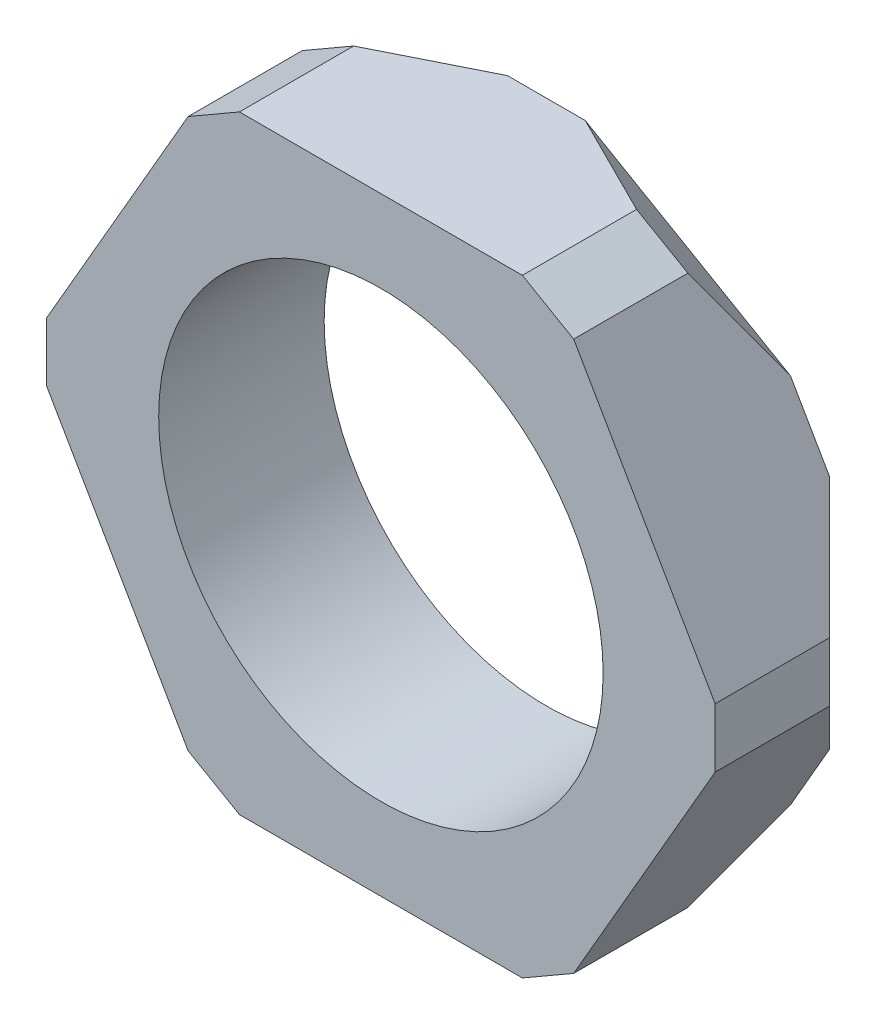
from build123d import *

# Parameters (mm, degrees)
SKETCH1_R           = 6.5
BOSS_EXTRUDE1_DEPTH = 4.84
CHAMFER1_SIZE       = 1
CHAMFER2_SIZE       = 1.5


with BuildPart() as part:
    # Sketch1 → Boss-Extrude1 (new body)
    with BuildSketch(Plane.XY):
        Polygon((5.138417396, 8.9), (-5.138417396, 8.9), (-10.276834792, 0), (-5.138417396, -8.9), (5.138417396, -8.9), (10.276834792, 0), align=None)
        Circle(SKETCH1_R, mode=Mode.SUBTRACT)
    extrude(amount=BOSS_EXTRUDE1_DEPTH)

    # Chamfer1
    chamfer1_edges = [part.edges().sort_by_distance(p)[0] for p in [
        (10.276834792, 0, 2.42),
        (5.138417396, -8.9, 2.42),
        (-5.138417396, -8.9, 2.42),
        (-10.276834792, 0, 2.42),
        (-5.138417396, 8.9, 2.42),
        (5.138417396, 8.9, 2.42),
    ]]
    chamfer(chamfer1_edges, length=CHAMFER1_SIZE)

    # Chamfer2
    chamfer2_edges = [part.edges().sort_by_distance(p)[0] for p in [
        (4.888417396, 8.466987298, 0),
        (9.776834792, 0, 0),
        (-4.888417396, 8.466987298, 0),
        (-9.776834792, 0, 0),
        (-4.888417396, -8.466987298, 0),
        (4.888417396, -8.466987298, 0),
    ]]
    chamfer(chamfer2_edges, length=CHAMFER2_SIZE)


solid = part.part
